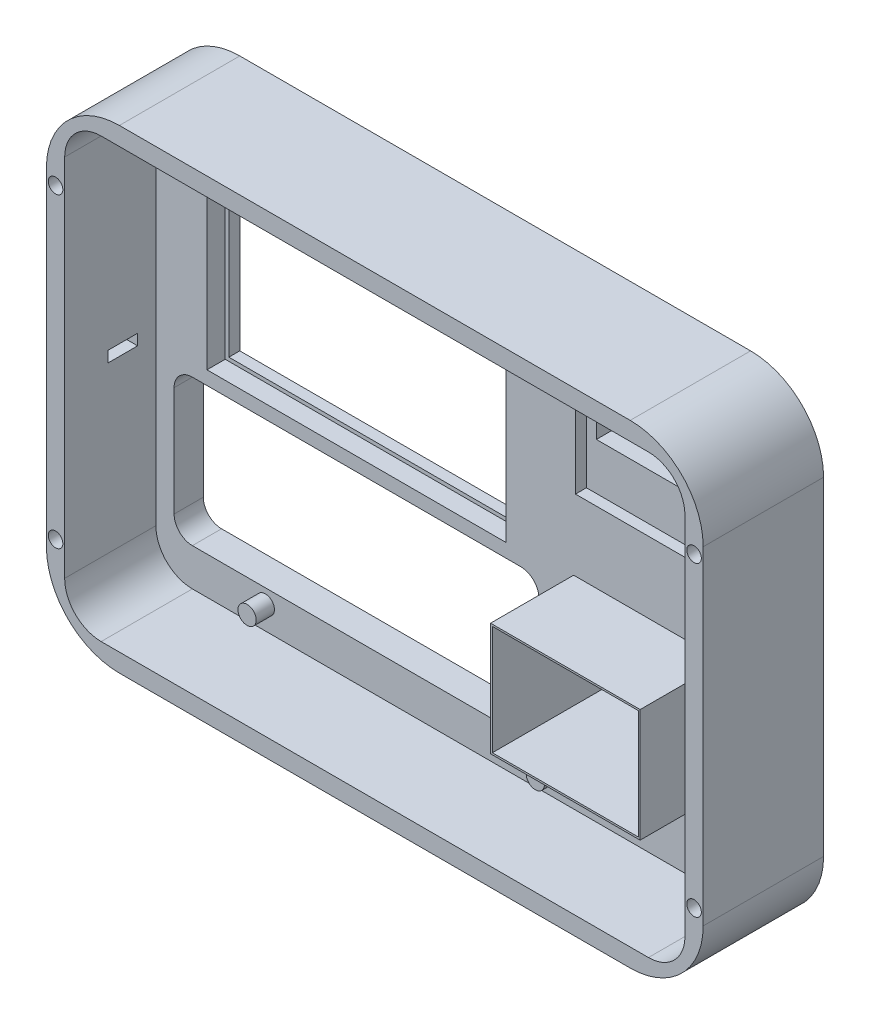
from build123d import *

# Parameters (mm, degrees)
SKETCH2_W           = 40
SKETCH2_H           = 30
SKETCH2_W_2         = 80
SKETCH2_H_2         = 50
SKETCH2_W_3         = 34.54
SKETCH2_H_3         = 5
BOSS_EXTRUDE5_DEPTH = 33
CUT_EXTRUDE1_DEPTH  = 25
SKETCH5_W           = 40
SKETCH5_H           = 40
CUT_EXTRUDE2_DEPTH  = 3
SKETCH6_W           = 41
SKETCH6_H           = 31
SKETCH6_W_2         = 40
SKETCH6_H_2         = 30
BOSS_EXTRUDE6_DEPTH = 30
SKETCH7_W           = 82
SKETCH7_H           = 52
SKETCH7_W_2         = 80
SKETCH7_H_2         = 50
CUT_EXTRUDE3_DEPTH  = 5
SKETCH8_R           = 2.5
BOSS_EXTRUDE7_DEPTH = 5
SKETCH10_W          = 7.223837829
SKETCH10_H          = 31
CUT_EXTRUDE6_DEPTH  = 41
SKETCH14_R          = 2
CUT_EXTRUDE9_DEPTH  = 20
SKETCH9_W           = 8.06
SKETCH9_H           = 3
CUT_EXTRUDE11_DEPTH = 5


with BuildPart() as part:
    # Sketch2 → Boss-Extrude5 (new body)
    with BuildSketch(Plane.XY):
        with BuildLine():
            ThreePointArc((-76.48364315, 74.732394366), (-90.625778773, 68.87452999), (-96.48364315, 54.732394366))
            Line((-96.48364315, 54.732394366), (-96.48364315, -35.267605634))
            ThreePointArc((-96.48364315, -35.267605634), (-90.625778773, -49.409741258), (-76.48364315, -55.267605634))
            Line((-76.48364315, -55.267605634), (63.51635685, -55.267605634))
            ThreePointArc((63.51635685, -55.267605634), (77.658492474, -49.409741258), (83.51635685, -35.267605634))
            Line((83.51635685, -35.267605634), (83.51635685, 54.732394366))
            ThreePointArc((83.51635685, 54.732394366), (77.658492474, 68.87452999), (63.51635685, 74.732394366))
            Line((63.51635685, 74.732394366), (-76.48364315, 74.732394366))
        make_face()
        with Locations((43.51635685, -10.267605634)):
            Rectangle(SKETCH2_W, SKETCH2_H, mode=Mode.SUBTRACT)
        with BuildLine():
            ThreePointArc((-86.48364315, -5), (-85.019177056, -1.464466094), (-81.48364315, 0))
            Line((-81.48364315, 0), (8.51635685, 0))
            ThreePointArc((8.51635685, 0), (12.051890756, -1.464466094), (13.51635685, -5))
            Line((13.51635685, -5), (13.51635685, -35))
            ThreePointArc((13.51635685, -35), (12.051890756, -38.535533906), (8.51635685, -40))
            Line((8.51635685, -40), (-81.48364315, -40))
            ThreePointArc((-81.48364315, -40), (-85.019177056, -38.535533906), (-86.48364315, -35))
            Line((-86.48364315, -35), (-86.48364315, -5))
        make_face(mode=Mode.SUBTRACT)
        with Locations((-36.48364315, 29.732394366)):
            Rectangle(SKETCH2_W_2, SKETCH2_H_2, mode=Mode.SUBTRACT)
        with Locations((43.51635685, 50.069459439)):
            Rectangle(SKETCH2_W_3, SKETCH2_H_3, mode=Mode.SUBTRACT)
        with Locations((43.51635685, 40.069459439)):
            Rectangle(SKETCH2_W_3, SKETCH2_H_3, mode=Mode.SUBTRACT)
    extrude(amount=BOSS_EXTRUDE5_DEPTH)

    # Sketch4 → Cut-Extrude1 (cut)
    with BuildSketch(Plane.XY.offset(33)):
        with BuildLine():
            Line((-81.48364315, 69.732394366), (68.51635685, 69.732394366))
            ThreePointArc((68.51635685, 69.732394366), (75.587424662, 66.803462178), (78.51635685, 59.732394366))
            Line((78.51635685, 59.732394366), (78.51635685, -40.267605634))
            ThreePointArc((78.51635685, -40.267605634), (75.587424662, -47.338673446), (68.51635685, -50.267605634))
            Line((68.51635685, -50.267605634), (-81.48364315, -50.267605634))
            ThreePointArc((-81.48364315, -50.267605634), (-88.554710961, -47.338673446), (-91.48364315, -40.267605634))
            Line((-91.48364315, -40.267605634), (-91.48364315, 59.732394366))
            ThreePointArc((-91.48364315, 59.732394366), (-88.554710961, 66.803462178), (-81.48364315, 69.732394366))
        make_face()
    extrude(amount=-CUT_EXTRUDE1_DEPTH, mode=Mode.SUBTRACT)

    # Sketch5 → Cut-Extrude2 (cut)
    with BuildSketch(Plane.XY.offset(8)):
        with Locations((43.51635685, 44.732394366)):
            Rectangle(SKETCH5_W, SKETCH5_H)
    extrude(amount=-CUT_EXTRUDE2_DEPTH, mode=Mode.SUBTRACT)

    # Sketch6 → Boss-Extrude6 (add)
    with BuildSketch(Plane.XY.offset(8)):
        with Locations((43.51635685, -10.267605634)):
            Rectangle(SKETCH6_W, SKETCH6_H)
        with Locations((43.51635685, -10.267605634)):
            Rectangle(SKETCH6_W_2, SKETCH6_H_2, mode=Mode.SUBTRACT)
    extrude(amount=BOSS_EXTRUDE6_DEPTH)

    # Sketch7 → Cut-Extrude3 (cut)
    with BuildSketch(Plane.XY.offset(8)):
        with Locations((-36.48364315, 29.732394366)):
            Rectangle(SKETCH7_W, SKETCH7_H)
        with Locations((-36.48364315, 29.732394366)):
            Rectangle(SKETCH7_W_2, SKETCH7_H_2, mode=Mode.SUBTRACT)
    extrude(amount=-CUT_EXTRUDE3_DEPTH, mode=Mode.SUBTRACT)

    # Sketch8 → Boss-Extrude7 (add)
    with BuildSketch(Plane.XY.offset(8)):
        with Locations((-77.48364315, 65.732394366)):
            Circle(SKETCH8_R)
        with Locations((17.51635685, 65.732394366)):
            Circle(SKETCH8_R)
        with Locations((-61.48364315, -43.947605634)):
            Circle(SKETCH8_R)
        with Locations((17.51635685, -43.447605634)):
            Circle(SKETCH8_R)
    extrude(amount=BOSS_EXTRUDE7_DEPTH)

    # Sketch10 → Cut-Extrude6 (cut)
    with BuildSketch(Plane.ZY.offset(-23.01635685)):
        with Locations((34.388081086, -10.267605634)):
            Rectangle(SKETCH10_W, SKETCH10_H)
    extrude(amount=-CUT_EXTRUDE6_DEPTH, mode=Mode.SUBTRACT)

    # Sketch14 → Cut-Extrude9 (cut)
    with BuildSketch(Plane.XY.offset(33)):
        with Locations((-93.98364315, 51.732394366)):
            Circle(SKETCH14_R)
        with Locations((81.01635685, 51.732394366)):
            Circle(SKETCH14_R)
        with Locations((81.01635685, -32.267605634)):
            Circle(SKETCH14_R)
        with Locations((-93.98364315, -32.267605634)):
            Circle(SKETCH14_R)
    extrude(amount=-CUT_EXTRUDE9_DEPTH, mode=Mode.SUBTRACT)

    # Sketch9 → Cut-Extrude11 (cut)
    with BuildSketch(Plane.ZY.offset(96.48364315)):
        with Locations((17.03, 6.418155037)):
            Rectangle(SKETCH9_W, SKETCH9_H)
    extrude(amount=-CUT_EXTRUDE11_DEPTH, mode=Mode.SUBTRACT)


solid = part.part
